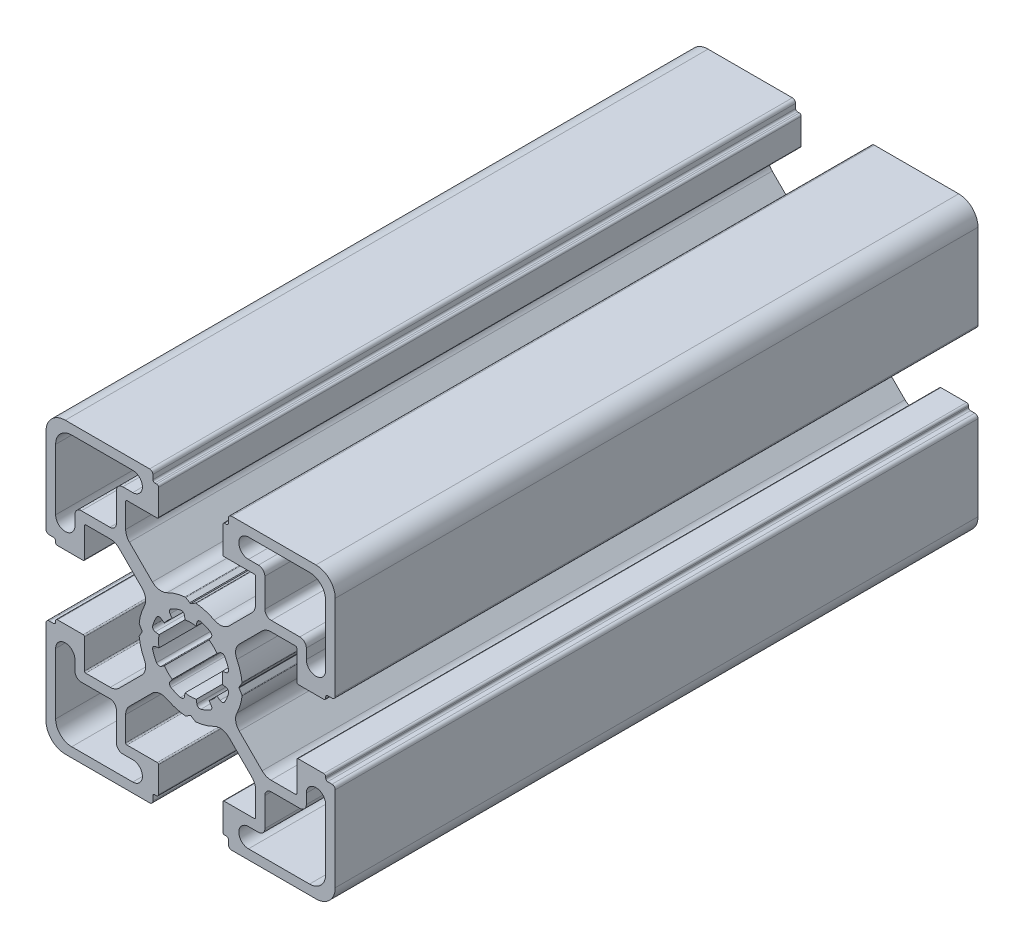
from build123d import *

# Parameters (mm, degrees)
BASE_EXTRUDE_DEPTH = 100


with BuildPart() as part:
    # Sketch1 → Base-Extrude (new body)
    with BuildSketch(Plane.XY):
        with BuildLine():
            Line((7.973976585, 0.792591518), (7.540060475, 0.046829556))
            ThreePointArc((7.540060475, 0.046829556), (7.534295984, 0.023675638), (7.531329941, 0))
            ThreePointArc((7.531329941, 0), (7.534295984, -0.023675638), (7.540060475, -0.046829556))
            Line((7.540060475, -0.046829556), (7.973976585, -0.792591518))
            ThreePointArc((7.973976585, -0.792591518), (7.996666421, -0.851255641), (8.000014047, -0.914065683))
            ThreePointArc((8.000014047, -0.914065683), (7.719730741, -2.298395946), (7.20036345, -3.611859543))
            ThreePointArc((7.20036345, -3.611859543), (7.018857217, -4.793954471), (7.563483933, -5.85869607))
            Line((7.563483933, -5.85869607), (11.129779889, -9.424988026))
            ThreePointArc((11.129779889, -9.424988026), (11.760624613, -9.84650461), (12.504756513, -9.99452154))
            Line((12.504756513, -9.99452154), (16.316902451, -9.99452154))
            ThreePointArc((16.316902451, -9.99452154), (16.458324055, -9.935942793), (16.516902802, -9.794521189))
            Line((16.516902802, -9.794521189), (16.516902802, -5.200014226))
            ThreePointArc((16.516902802, -5.200014226), (16.575481548, -5.058592621), (16.716903152, -5.000013875))
            Line((16.716903152, -5.000013875), (20.719599904, -5.000013875))
            ThreePointArc((20.719599904, -5.000013875), (20.931731427, -5.087881629), (21.01959918, -5.300013151))
            Line((21.01959918, -5.300013151), (21.01959918, -5.500004099))
            ThreePointArc((21.01959918, -5.500004099), (21.10746708, -5.712135974), (21.319598956, -5.800003874))
            Line((21.319598956, -5.800003874), (21.999979514, -5.800003874))
            ThreePointArc((21.999979514, -5.800003874), (22.35353264, -5.946450374), (22.49997914, -6.300003501))
            Line((22.49997914, -6.300003501), (22.49997914, -19.500016116))
            ThreePointArc((22.49997914, -19.500016116), (21.62130014, -21.621334875), (19.499981381, -22.500013875))
            Line((19.499981381, -22.500013875), (6.375709012, -22.500013875))
            ThreePointArc((6.375709012, -22.500013875), (6.022155886, -22.353567375), (5.875709386, -22.000014249))
            Line((5.875709386, -22.000014249), (5.875709386, -21.30001315))
            ThreePointArc((5.875709386, -21.30001315), (5.787841632, -21.087881628), (5.57571011, -21.000013874))
            Line((5.57571011, -21.000013874), (5.299998776, -21.000013874))
            ThreePointArc((5.299998776, -21.000013874), (5.087867607, -20.912146267), (5, -20.700015099))
            Line((5, -20.700015099), (5, -16.666812433))
            ThreePointArc((5, -16.666812433), (5.058578893, -16.525390475), (5.200000851, -16.466811582))
            Line((5.200000851, -16.466811582), (9.905385218, -16.466811582))
            ThreePointArc((9.905385218, -16.466811582), (10.046806822, -16.408232835), (10.105385569, -16.266811231))
            Line((10.105385569, -16.266811231), (10.105385569, -12.471582956))
            ThreePointArc((10.105385569, -12.471582956), (9.953144588, -11.706215861), (9.519598955, -11.057368968))
            Line((9.519598955, -11.057368968), (5.944897989, -7.482668002))
            ThreePointArc((5.944897989, -7.482668002), (4.854601835, -6.967833724), (3.666499237, -7.173289937))
            ThreePointArc((3.666499237, -7.173289937), (2.309136684, -7.713848333), (0.876396038, -8.000013875))
            ThreePointArc((0.876396038, -8.000013875), (0.81356491, -7.997088573), (0.754749577, -7.974793627))
            Line((0.754749577, -7.974793627), (0.11262846, -7.606936933))
            ThreePointArc((0.11262846, -7.606936933), (0.062963903, -7.559088739), (0, -7.530953975))
            ThreePointArc((0, -7.530953975), (-0.062963903, -7.559088739), (-0.11262846, -7.606936933))
            Line((-0.11262846, -7.606936933), (-0.754749577, -7.974793627))
            ThreePointArc((-0.754749577, -7.974793627), (-0.81356491, -7.997088573), (-0.876396038, -8.000013875))
            ThreePointArc((-0.876396038, -8.000013875), (-2.309136684, -7.713848333), (-3.666499237, -7.173289937))
            ThreePointArc((-3.666499237, -7.173289937), (-4.854601835, -6.967833724), (-5.944897989, -7.482668002))
            Line((-5.944897989, -7.482668002), (-9.519598955, -11.057368968))
            ThreePointArc((-9.519598955, -11.057368968), (-9.953144588, -11.706215861), (-10.105385569, -12.471582956))
            Line((-10.105385569, -12.471582956), (-10.105385569, -16.266811231))
            ThreePointArc((-10.105385569, -16.266811231), (-10.046806822, -16.408232835), (-9.905385218, -16.466811582))
            Line((-9.905385218, -16.466811582), (-5.200000851, -16.466811582))
            ThreePointArc((-5.200000851, -16.466811582), (-5.058578893, -16.525390475), (-5, -16.666812433))
            Line((-5, -16.666812433), (-5, -20.700015099))
            ThreePointArc((-5, -20.700015099), (-5.087867607, -20.912146267), (-5.299998776, -21.000013874))
            Line((-5.299998776, -21.000013874), (-5.57571011, -21.000013874))
            ThreePointArc((-5.57571011, -21.000013874), (-5.787841632, -21.087881628), (-5.875709386, -21.30001315))
            Line((-5.875709386, -21.30001315), (-5.875709386, -22.000014249))
            ThreePointArc((-5.875709386, -22.000014249), (-6.022155886, -22.353567375), (-6.375709012, -22.500013875))
            Line((-6.375709012, -22.500013875), (-19.499981381, -22.500013875))
            ThreePointArc((-19.499981381, -22.500013875), (-21.62130014, -21.621334875), (-22.49997914, -19.500016116))
            Line((-22.49997914, -19.500016116), (-22.49997914, -6.300003501))
            ThreePointArc((-22.49997914, -6.300003501), (-22.35353264, -5.946450374), (-21.999979514, -5.800003874))
            Line((-21.999979514, -5.800003874), (-21.319598956, -5.800003874))
            ThreePointArc((-21.319598956, -5.800003874), (-21.10746708, -5.712135974), (-21.01959918, -5.500004099))
            Line((-21.01959918, -5.500004099), (-21.01959918, -5.300013151))
            ThreePointArc((-21.01959918, -5.300013151), (-20.931731427, -5.087881629), (-20.719599904, -5.000013875))
            Line((-20.719599904, -5.000013875), (-16.716903152, -5.000013875))
            ThreePointArc((-16.716903152, -5.000013875), (-16.575481548, -5.058592621), (-16.516902802, -5.200014226))
            Line((-16.516902802, -5.200014226), (-16.516902802, -9.794521189))
            ThreePointArc((-16.516902802, -9.794521189), (-16.458324055, -9.935942793), (-16.316902451, -9.99452154))
            Line((-16.316902451, -9.99452154), (-12.504756513, -9.99452154))
            ThreePointArc((-12.504756513, -9.99452154), (-11.760624613, -9.84650461), (-11.129779889, -9.424988026))
            Line((-11.129779889, -9.424988026), (-7.563483933, -5.85869607))
            ThreePointArc((-7.563483933, -5.85869607), (-7.018857217, -4.793954471), (-7.20036345, -3.611859543))
            ThreePointArc((-7.20036345, -3.611859543), (-7.719730741, -2.298395946), (-8.000014047, -0.914065683))
            ThreePointArc((-8.000014047, -0.914065683), (-7.996666421, -0.851255641), (-7.973976585, -0.792591518))
            Line((-7.973976585, -0.792591518), (-7.540060475, -0.046829556))
            ThreePointArc((-7.540060475, -0.046829556), (-7.534295984, -0.023675638), (-7.531329941, 0))
            ThreePointArc((-7.531329941, 0), (-7.534295984, 0.023675638), (-7.540060475, 0.046829556))
            Line((-7.540060475, 0.046829556), (-7.973976585, 0.792591518))
            ThreePointArc((-7.973976585, 0.792591518), (-7.996666421, 0.851255641), (-8.000014047, 0.914065683))
            ThreePointArc((-8.000014047, 0.914065683), (-7.719730741, 2.298395946), (-7.20036345, 3.611859543))
            ThreePointArc((-7.20036345, 3.611859543), (-7.018857217, 4.793954471), (-7.563483933, 5.85869607))
            Line((-7.563483933, 5.85869607), (-11.129779889, 9.424988026))
            ThreePointArc((-11.129779889, 9.424988026), (-11.760624613, 9.84650461), (-12.504756513, 9.99452154))
            Line((-12.504756513, 9.99452154), (-16.316902451, 9.99452154))
            ThreePointArc((-16.316902451, 9.99452154), (-16.458324055, 9.935942793), (-16.516902802, 9.794521189))
            Line((-16.516902802, 9.794521189), (-16.516902802, 5.200014226))
            ThreePointArc((-16.516902802, 5.200014226), (-16.575481548, 5.058592621), (-16.716903152, 5.000013875))
            Line((-16.716903152, 5.000013875), (-20.719599904, 5.000013875))
            ThreePointArc((-20.719599904, 5.000013875), (-20.931731427, 5.087881629), (-21.01959918, 5.300013151))
            Line((-21.01959918, 5.300013151), (-21.01959918, 5.500004099))
            ThreePointArc((-21.01959918, 5.500004099), (-21.10746708, 5.712135974), (-21.319598956, 5.800003874))
            Line((-21.319598956, 5.800003874), (-21.999979514, 5.800003874))
            ThreePointArc((-21.999979514, 5.800003874), (-22.35353264, 5.946450374), (-22.49997914, 6.300003501))
            Line((-22.49997914, 6.300003501), (-22.49997914, 19.500016116))
            ThreePointArc((-22.49997914, 19.500016116), (-21.62130014, 21.621334875), (-19.499981381, 22.500013875))
            Line((-19.499981381, 22.500013875), (-6.375709012, 22.500013875))
            ThreePointArc((-6.375709012, 22.500013875), (-6.022155886, 22.353567375), (-5.875709386, 22.000014249))
            Line((-5.875709386, 22.000014249), (-5.875709386, 21.30001315))
            ThreePointArc((-5.875709386, 21.30001315), (-5.787841632, 21.087881628), (-5.57571011, 21.000013874))
            Line((-5.57571011, 21.000013874), (-5.299998776, 21.000013874))
            ThreePointArc((-5.299998776, 21.000013874), (-5.087867607, 20.912146267), (-5, 20.700015099))
            Line((-5, 20.700015099), (-5, 16.666812433))
            ThreePointArc((-5, 16.666812433), (-5.058578893, 16.525390475), (-5.200000851, 16.466811582))
            Line((-5.200000851, 16.466811582), (-9.905385218, 16.466811582))
            ThreePointArc((-9.905385218, 16.466811582), (-10.046806822, 16.408232835), (-10.105385569, 16.266811231))
            Line((-10.105385569, 16.266811231), (-10.105385569, 12.471582956))
            ThreePointArc((-10.105385569, 12.471582956), (-9.953144588, 11.706215861), (-9.519598955, 11.057368968))
            Line((-9.519598955, 11.057368968), (-5.944897989, 7.482668002))
            ThreePointArc((-5.944897989, 7.482668002), (-4.854601835, 6.967833724), (-3.666499237, 7.173289937))
            ThreePointArc((-3.666499237, 7.173289937), (-2.309136684, 7.713848333), (-0.876396038, 8.000013875))
            ThreePointArc((-0.876396038, 8.000013875), (-0.81356491, 7.997088573), (-0.754749577, 7.974793627))
            Line((-0.754749577, 7.974793627), (-0.11262846, 7.606936933))
            ThreePointArc((-0.11262846, 7.606936933), (-0.062963903, 7.559088739), (0, 7.530953975))
            ThreePointArc((0, 7.530953975), (0.062963903, 7.559088739), (0.11262846, 7.606936933))
            Line((0.11262846, 7.606936933), (0.754749577, 7.974793627))
            ThreePointArc((0.754749577, 7.974793627), (0.81356491, 7.997088573), (0.876396038, 8.000013875))
            ThreePointArc((0.876396038, 8.000013875), (2.309136684, 7.713848333), (3.666499237, 7.173289937))
            ThreePointArc((3.666499237, 7.173289937), (4.854601835, 6.967833724), (5.944897989, 7.482668002))
            Line((5.944897989, 7.482668002), (9.519598955, 11.057368968))
            ThreePointArc((9.519598955, 11.057368968), (9.953144588, 11.706215861), (10.105385569, 12.471582956))
            Line((10.105385569, 12.471582956), (10.105385569, 16.266811231))
            ThreePointArc((10.105385569, 16.266811231), (10.046806822, 16.408232835), (9.905385218, 16.466811582))
            Line((9.905385218, 16.466811582), (5.200000851, 16.466811582))
            ThreePointArc((5.200000851, 16.466811582), (5.058578893, 16.525390475), (5, 16.666812433))
            Line((5, 16.666812433), (5, 20.700015099))
            ThreePointArc((5, 20.700015099), (5.087867607, 20.912146267), (5.299998776, 21.000013874))
            Line((5.299998776, 21.000013874), (5.57571011, 21.000013874))
            ThreePointArc((5.57571011, 21.000013874), (5.787841632, 21.087881628), (5.875709386, 21.30001315))
            Line((5.875709386, 21.30001315), (5.875709386, 22.000014249))
            ThreePointArc((5.875709386, 22.000014249), (6.022155886, 22.353567375), (6.375709012, 22.500013875))
            Line((6.375709012, 22.500013875), (19.499981381, 22.500013875))
            ThreePointArc((19.499981381, 22.500013875), (21.62130014, 21.621334875), (22.49997914, 19.500016116))
            Line((22.49997914, 19.500016116), (22.49997914, 6.300003501))
            ThreePointArc((22.49997914, 6.300003501), (22.35353264, 5.946450374), (21.999979514, 5.800003874))
            Line((21.999979514, 5.800003874), (21.319598956, 5.800003874))
            ThreePointArc((21.319598956, 5.800003874), (21.10746708, 5.712135974), (21.01959918, 5.500004099))
            Line((21.01959918, 5.500004099), (21.01959918, 5.300013151))
            ThreePointArc((21.01959918, 5.300013151), (20.931731427, 5.087881629), (20.719599904, 5.000013875))
            Line((20.719599904, 5.000013875), (16.716903152, 5.000013875))
            ThreePointArc((16.716903152, 5.000013875), (16.575481548, 5.058592621), (16.516902802, 5.200014226))
            Line((16.516902802, 5.200014226), (16.516902802, 9.794521189))
            ThreePointArc((16.516902802, 9.794521189), (16.458324055, 9.935942793), (16.316902451, 9.99452154))
            Line((16.316902451, 9.99452154), (12.504756513, 9.99452154))
            ThreePointArc((12.504756513, 9.99452154), (11.760624613, 9.84650461), (11.129779889, 9.424988026))
            Line((11.129779889, 9.424988026), (7.563483933, 5.85869607))
            ThreePointArc((7.563483933, 5.85869607), (7.018857217, 4.793954471), (7.20036345, 3.611859543))
            ThreePointArc((7.20036345, 3.611859543), (7.719730741, 2.298395946), (8.000014047, 0.914065683))
            ThreePointArc((8.000014047, 0.914065683), (7.996666421, 0.851255641), (7.973976585, 0.792591518))
        make_face()
        with BuildLine():
            Line((10.549978885, 18.000013874), (8.999979138, 18.000013874))
            ThreePointArc((8.999979138, 18.000013874), (7.499979138, 19.500013874), (8.999979138, 21.000013874))
            Line((8.999979138, 21.000013874), (18.499981006, 21.000013874))
            ThreePointArc((18.499981006, 21.000013874), (20.267746638, 20.267781374), (20.999979138, 18.500015742))
            Line((20.999979138, 18.500015742), (20.999979138, 9.000204874))
            ThreePointArc((20.999979138, 9.000204874), (19.499979138, 7.500204874), (17.999979138, 9.000204874))
            Line((17.999979138, 9.000204874), (17.999979138, 10.550013621))
            ThreePointArc((17.999979138, 10.550013621), (17.707086138, 11.257119874), (16.999979885, 11.550012874))
            Line((16.999979885, 11.550012874), (12.549977391, 11.550012874))
            ThreePointArc((12.549977391, 11.550012874), (11.842871138, 11.842905874), (11.549978138, 12.550012127))
            Line((11.549978138, 12.550012127), (11.549978138, 17.000014621))
            ThreePointArc((11.549978138, 17.000014621), (11.257085138, 17.707120874), (10.549978885, 18.000013874))
        make_face(mode=Mode.SUBTRACT)
        with BuildLine():
            Line((-0.867388737, 4.924188946), (-0.96752168, 5.481112935))
            ThreePointArc((-0.96752168, 5.481112935), (-1.187855719, 5.829589164), (-1.595071417, 5.894072848))
            ThreePointArc((-1.595071417, 5.894072848), (-2.338895973, 5.643477696), (-3.04438497, 5.299445466))
            ThreePointArc((-3.04438497, 5.299445466), (-3.284615367, 4.964275075), (-3.191311906, 4.562598216))
            Line((-3.191311906, 4.562598216), (-2.864000421, 4.09847552))
            ThreePointArc((-2.864000421, 4.09847552), (-3.53013295, 3.540926624), (-4.08971289, 2.876499344))
            Line((-4.08971289, 2.876499344), (-4.566777651, 3.208162503))
            ThreePointArc((-4.566777651, 3.208162503), (-4.968960845, 3.298770682), (-5.302497889, 3.056460542))
            ThreePointArc((-5.302497889, 3.056460542), (-5.651259984, 2.353310881), (-5.906847665, 1.611199444))
            ThreePointArc((-5.906847665, 1.611199444), (-5.839752063, 1.204293023), (-5.489730697, 0.98621116))
            Line((-5.489730697, 0.98621116), (-4.920545766, 0.887822825))
            ThreePointArc((-4.920545766, 0.887822825), (-4.980096828, 0.445685524), (-5, 0))
            ThreePointArc((-5, 0), (-4.980096828, -0.445685524), (-4.920545766, -0.887822825))
            Line((-4.920545766, -0.887822825), (-5.489730697, -0.98621116))
            ThreePointArc((-5.489730697, -0.98621116), (-5.839752063, -1.204293023), (-5.906847665, -1.611199444))
            ThreePointArc((-5.906847665, -1.611199444), (-5.651259984, -2.353310881), (-5.302497889, -3.056460542))
            ThreePointArc((-5.302497889, -3.056460542), (-4.968960845, -3.298770682), (-4.566777651, -3.208162503))
            Line((-4.566777651, -3.208162503), (-4.08971289, -2.876499344))
            ThreePointArc((-4.08971289, -2.876499344), (-3.53013295, -3.540926624), (-2.864000421, -4.09847552))
            Line((-2.864000421, -4.09847552), (-3.191311906, -4.562598216))
            ThreePointArc((-3.191311906, -4.562598216), (-3.284615367, -4.964275075), (-3.04438497, -5.299445466))
            ThreePointArc((-3.04438497, -5.299445466), (-2.338895973, -5.643477696), (-1.595071417, -5.894072848))
            ThreePointArc((-1.595071417, -5.894072848), (-1.187855719, -5.829589164), (-0.96752168, -5.481112935))
            Line((-0.96752168, -5.481112935), (-0.867388737, -4.924188946))
            ThreePointArc((-0.867388737, -4.924188946), (0, -5), (0.867388737, -4.924188946))
            Line((0.867388737, -4.924188946), (0.96752168, -5.481112935))
            ThreePointArc((0.96752168, -5.481112935), (1.187855719, -5.829589164), (1.595071417, -5.894072848))
            ThreePointArc((1.595071417, -5.894072848), (2.338895973, -5.643477696), (3.04438497, -5.299445466))
            ThreePointArc((3.04438497, -5.299445466), (3.284615367, -4.964275075), (3.191311906, -4.562598216))
            Line((3.191311906, -4.562598216), (2.864000421, -4.09847552))
            ThreePointArc((2.864000421, -4.09847552), (3.53013295, -3.540926624), (4.08971289, -2.876499344))
            Line((4.08971289, -2.876499344), (4.566777651, -3.208162503))
            ThreePointArc((4.566777651, -3.208162503), (4.968960845, -3.298770682), (5.302497889, -3.056460542))
            ThreePointArc((5.302497889, -3.056460542), (5.651259984, -2.353310881), (5.906847665, -1.611199444))
            ThreePointArc((5.906847665, -1.611199444), (5.839752063, -1.204293023), (5.489730697, -0.98621116))
            Line((5.489730697, -0.98621116), (4.920545766, -0.887822825))
            ThreePointArc((4.920545766, -0.887822825), (4.980096828, -0.445685524), (5, 0))
            ThreePointArc((5, 0), (4.980096828, 0.445685524), (4.920545766, 0.887822825))
            Line((4.920545766, 0.887822825), (5.489730697, 0.98621116))
            ThreePointArc((5.489730697, 0.98621116), (5.839752063, 1.204293023), (5.906847665, 1.611199444))
            ThreePointArc((5.906847665, 1.611199444), (5.651259984, 2.353310881), (5.302497889, 3.056460542))
            ThreePointArc((5.302497889, 3.056460542), (4.968960845, 3.298770682), (4.566777651, 3.208162503))
            Line((4.566777651, 3.208162503), (4.08971289, 2.876499344))
            ThreePointArc((4.08971289, 2.876499344), (3.53013295, 3.540926624), (2.864000421, 4.09847552))
            Line((2.864000421, 4.09847552), (3.191311906, 4.562598216))
            ThreePointArc((3.191311906, 4.562598216), (3.284615367, 4.964275075), (3.04438497, 5.299445466))
            ThreePointArc((3.04438497, 5.299445466), (2.338895973, 5.643477696), (1.595071417, 5.894072848))
            ThreePointArc((1.595071417, 5.894072848), (1.187855719, 5.829589164), (0.96752168, 5.481112935))
            Line((0.96752168, 5.481112935), (0.867388737, 4.924188946))
            ThreePointArc((0.867388737, 4.924188946), (0, 5), (-0.867388737, 4.924188946))
        make_face(mode=Mode.SUBTRACT)
        with BuildLine():
            Line((-10.549978885, -18.000013874), (-8.999979138, -18.000013874))
            ThreePointArc((-8.999979138, -18.000013874), (-7.499979138, -19.500013874), (-8.999979138, -21.000013874))
            Line((-8.999979138, -21.000013874), (-18.499981006, -21.000013874))
            ThreePointArc((-18.499981006, -21.000013874), (-20.267746638, -20.267781374), (-20.999979138, -18.500015742))
            Line((-20.999979138, -18.500015742), (-20.999979138, -9.000204874))
            ThreePointArc((-20.999979138, -9.000204874), (-19.499979138, -7.500204874), (-17.999979138, -9.000204874))
            Line((-17.999979138, -9.000204874), (-17.999979138, -10.550013621))
            ThreePointArc((-17.999979138, -10.550013621), (-17.707086138, -11.257119874), (-16.999979885, -11.550012874))
            Line((-16.999979885, -11.550012874), (-12.549977391, -11.550012874))
            ThreePointArc((-12.549977391, -11.550012874), (-11.842871138, -11.842905874), (-11.549978138, -12.550012127))
            Line((-11.549978138, -12.550012127), (-11.549978138, -17.000014621))
            ThreePointArc((-11.549978138, -17.000014621), (-11.257085138, -17.707120874), (-10.549978885, -18.000013874))
        make_face(mode=Mode.SUBTRACT)
        with BuildLine():
            Line((-11.549978138, 12.550012127), (-11.549978138, 17.000014621))
            ThreePointArc((-11.549978138, 17.000014621), (-11.257085138, 17.707120874), (-10.549978885, 18.000013874))
            Line((-10.549978885, 18.000013874), (-8.999979138, 18.000013874))
            ThreePointArc((-8.999979138, 18.000013874), (-7.499979138, 19.500013874), (-8.999979138, 21.000013874))
            Line((-8.999979138, 21.000013874), (-18.499981006, 21.000013874))
            ThreePointArc((-18.499981006, 21.000013874), (-20.267746638, 20.267781374), (-20.999979138, 18.500015742))
            Line((-20.999979138, 18.500015742), (-20.999979138, 9.000204874))
            ThreePointArc((-20.999979138, 9.000204874), (-19.499979138, 7.500204874), (-17.999979138, 9.000204874))
            Line((-17.999979138, 9.000204874), (-17.999979138, 10.550013621))
            ThreePointArc((-17.999979138, 10.550013621), (-17.707086138, 11.257119874), (-16.999979885, 11.550012874))
            Line((-16.999979885, 11.550012874), (-12.549977391, 11.550012874))
            ThreePointArc((-12.549977391, 11.550012874), (-11.842871138, 11.842905874), (-11.549978138, 12.550012127))
        make_face(mode=Mode.SUBTRACT)
        with BuildLine():
            Line((11.549978138, -12.550012127), (11.549978138, -17.000014621))
            ThreePointArc((11.549978138, -17.000014621), (11.257085138, -17.707120874), (10.549978885, -18.000013874))
            Line((10.549978885, -18.000013874), (8.999979138, -18.000013874))
            ThreePointArc((8.999979138, -18.000013874), (7.499979138, -19.500013874), (8.999979138, -21.000013874))
            Line((8.999979138, -21.000013874), (18.499981006, -21.000013874))
            ThreePointArc((18.499981006, -21.000013874), (20.267746638, -20.267781374), (20.999979138, -18.500015742))
            Line((20.999979138, -18.500015742), (20.999979138, -9.000204874))
            ThreePointArc((20.999979138, -9.000204874), (19.499979138, -7.500204874), (17.999979138, -9.000204874))
            Line((17.999979138, -9.000204874), (17.999979138, -10.550013621))
            ThreePointArc((17.999979138, -10.550013621), (17.707086138, -11.257119874), (16.999979885, -11.550012874))
            Line((16.999979885, -11.550012874), (12.549977391, -11.550012874))
            ThreePointArc((12.549977391, -11.550012874), (11.842871138, -11.842905874), (11.549978138, -12.550012127))
        make_face(mode=Mode.SUBTRACT)
    extrude(amount=-BASE_EXTRUDE_DEPTH)


solid = part.part
